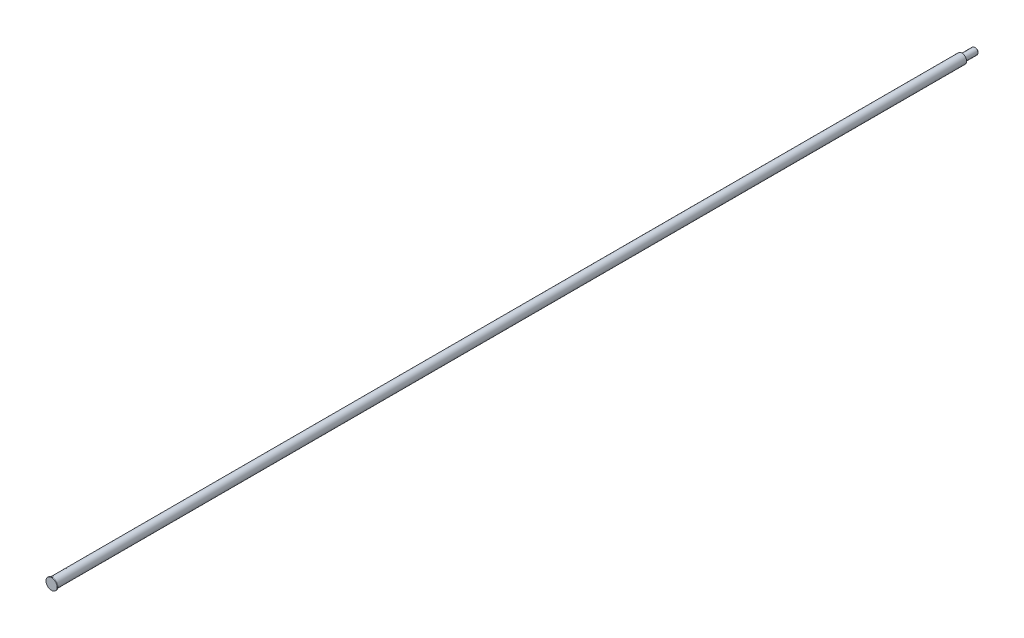
from build123d import *


with BuildPart() as part:
    # Esboço1 → Revolução1 (revolve)
    with BuildSketch(Plane.XZ):
        Polygon((10.25, 0), (0, 0), (0, -1703.1002), (4.75, -1703.1002), (6, -1701.8502), (6, -1679.3502), (4.75, -1678.1002), (8.75, -1678.1002), (8.75, -1.6002), (10.25, -1.6002), align=None)
    revolve(axis=Axis((0, 0, 0), (0, 0, -1)))


solid = part.part
